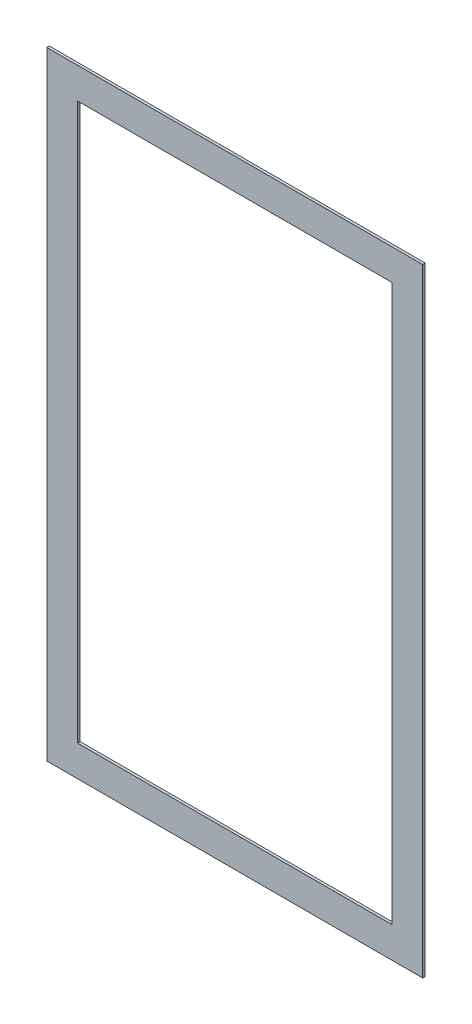
from build123d import *

# Parameters (mm, degrees)
SKETCH2_W           = 927.1
SKETCH2_H           = 1524
SKETCH2_W_2         = 774.7
SKETCH2_H_2         = 1371.6
BOSS_EXTRUDE1_DEPTH = 6.35


with BuildPart() as part:
    # Sketch2 → Boss-Extrude1 (new body)
    with BuildSketch(Plane.XY):
        Rectangle(SKETCH2_W, SKETCH2_H)
        Rectangle(SKETCH2_W_2, SKETCH2_H_2, mode=Mode.SUBTRACT)
    extrude(amount=BOSS_EXTRUDE1_DEPTH)


solid = part.part
